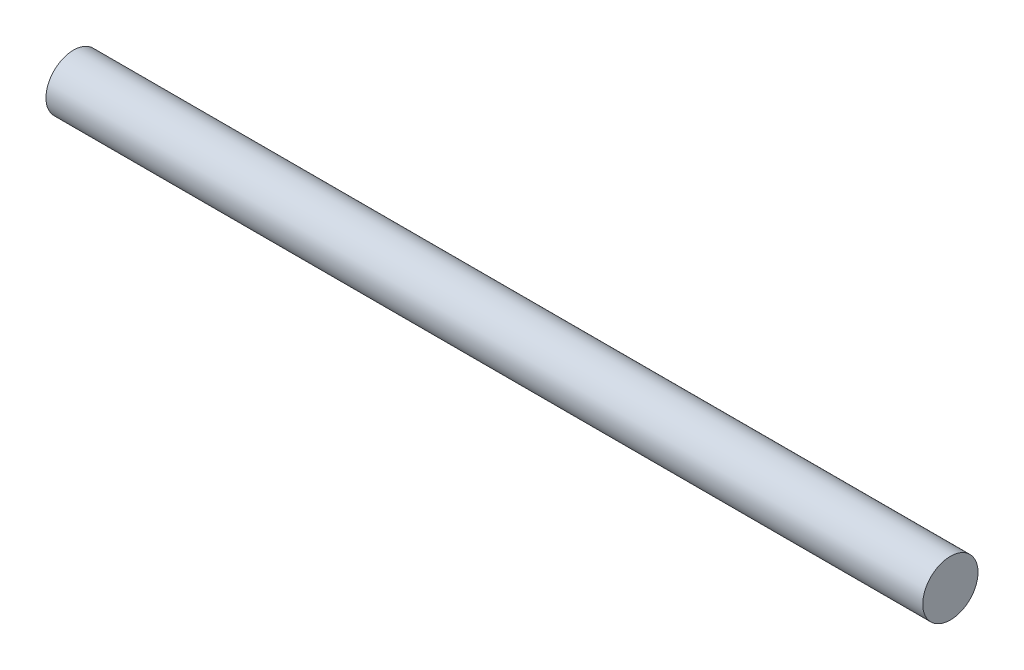
from build123d import *

# Parameters (mm, degrees)
SKETCH1_R           = 1.575
BOSS_EXTRUDE1_DEPTH = 50
ESCALA1_SCALE       = 0.5


with BuildPart() as part:
    # Sketch1 → Boss-Extrude1 (new body)
    with BuildSketch(Plane(origin=(0, 0, 0), x_dir=(0, 0, -1), z_dir=(1, 0, 0))):
        Circle(SKETCH1_R)
    extrude(amount=BOSS_EXTRUDE1_DEPTH)


with BuildPart() as part_1:
    # Escala1: scaled about (0, 0, 0)
    add(part.part.scale(ESCALA1_SCALE))


solid = part_1.part
